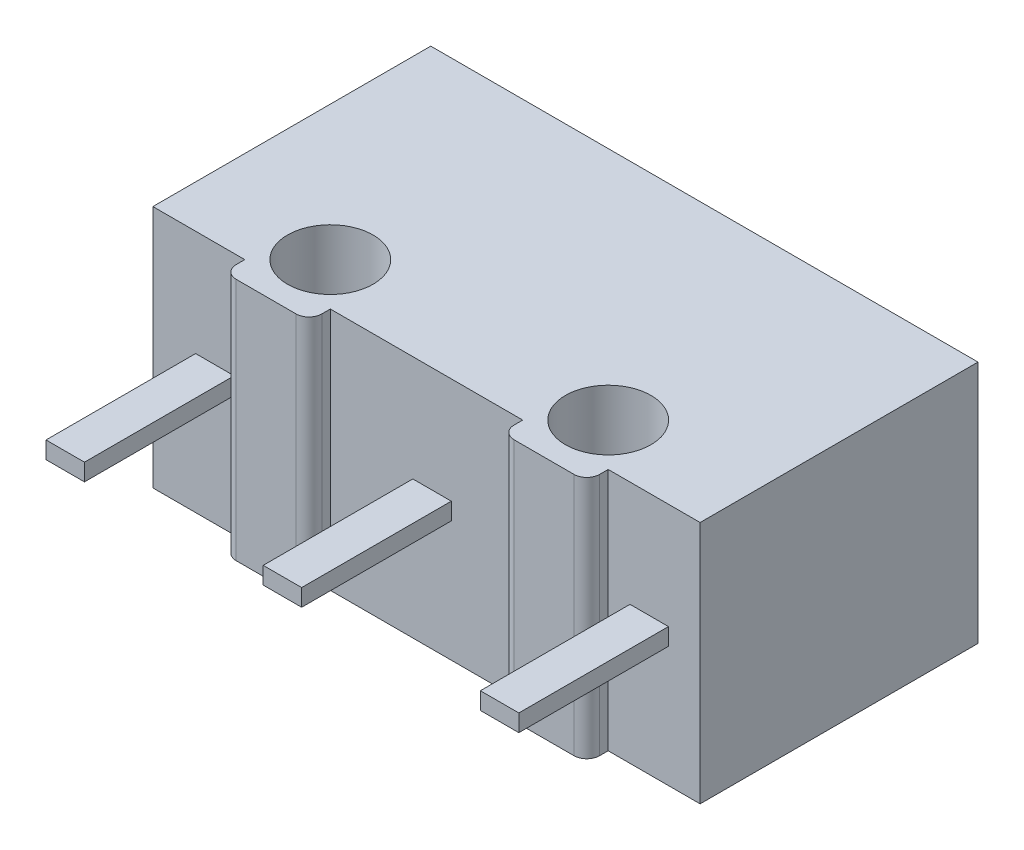
from build123d import *

# Parameters (mm, degrees)
SKETCH1_R           = 1
BOSS_EXTRUDE1_DEPTH = 5.7
SKETCH2_W           = 1.2
SKETCH2_H           = 2.9
BOSS_EXTRUDE2_DEPTH = 0.85
FILLET1_R           = 0.5
SKETCH3_W           = 0.9
SKETCH3_H           = 0.4
BOSS_EXTRUDE3_DEPTH = 3.5


with BuildPart() as part:
    # Sketch1 → Boss-Extrude1 (new body)
    with BuildSketch(Plane(origin=(0, 0, 0), x_dir=(1, 0, 0), z_dir=(0, 1, 0))):
        with BuildLine():
            Line((0, 0), (2.15, 0))
            Line((2.15, 0), (2.15, -0.2))
            ThreePointArc((2.15, -0.2), (2.237867966, -0.412132034), (2.45, -0.5))
            Line((2.45, -0.5), (3.85, -0.5))
            ThreePointArc((3.85, -0.5), (4.062132034, -0.412132034), (4.15, -0.2))
            Line((4.15, -0.2), (4.15, 0))
            Line((4.15, 0), (8.65, 0))
            Line((8.65, 0), (8.65, -0.2))
            ThreePointArc((8.65, -0.2), (8.737867966, -0.412132034), (8.95, -0.5))
            Line((8.95, -0.5), (10.35, -0.5))
            ThreePointArc((10.35, -0.5), (10.562132034, -0.412132034), (10.65, -0.2))
            Line((10.65, -0.2), (10.65, 0))
            Line((10.65, 0), (12.8, 0))
            Line((12.8, 0), (12.8, 6.5))
            Line((12.8, 6.5), (0, 6.5))
            Line((0, 6.5), (0, 0))
        make_face()
        with Locations((3.15, 1)):
            Circle(SKETCH1_R, mode=Mode.SUBTRACT)
        with Locations((9.65, 1)):
            Circle(SKETCH1_R, mode=Mode.SUBTRACT)
    extrude(amount=BOSS_EXTRUDE1_DEPTH)

    # Sketch2 → Boss-Extrude2 (add)
    with BuildSketch(Plane(origin=(0, 0, -6.5), x_dir=(-1, 0, 0), z_dir=(0, 0, -1))):
        with Locations((-8.35, 2.8)):
            Rectangle(SKETCH2_W, SKETCH2_H)
    extrude(amount=BOSS_EXTRUDE2_DEPTH)

    # Fillet1
    fillet1_edges = [part.edges().sort_by_distance(p)[0] for p in [
        (8.95, 2.8, -7.35),
        (7.75, 2.8, -7.35),
    ]]
    fillet(fillet1_edges, radius=FILLET1_R)

    # Sketch3 → Boss-Extrude3 (add)
    with BuildSketch(Plane.XY):
        with Locations((1.45, 3.022147262)):
            Rectangle(SKETCH3_W, SKETCH3_H)
        with Locations((6.53, 3.022147262)):
            Rectangle(SKETCH3_W, SKETCH3_H)
        with Locations((11.61, 3.022147262)):
            Rectangle(SKETCH3_W, SKETCH3_H)
    extrude(amount=BOSS_EXTRUDE3_DEPTH)


solid = part.part
